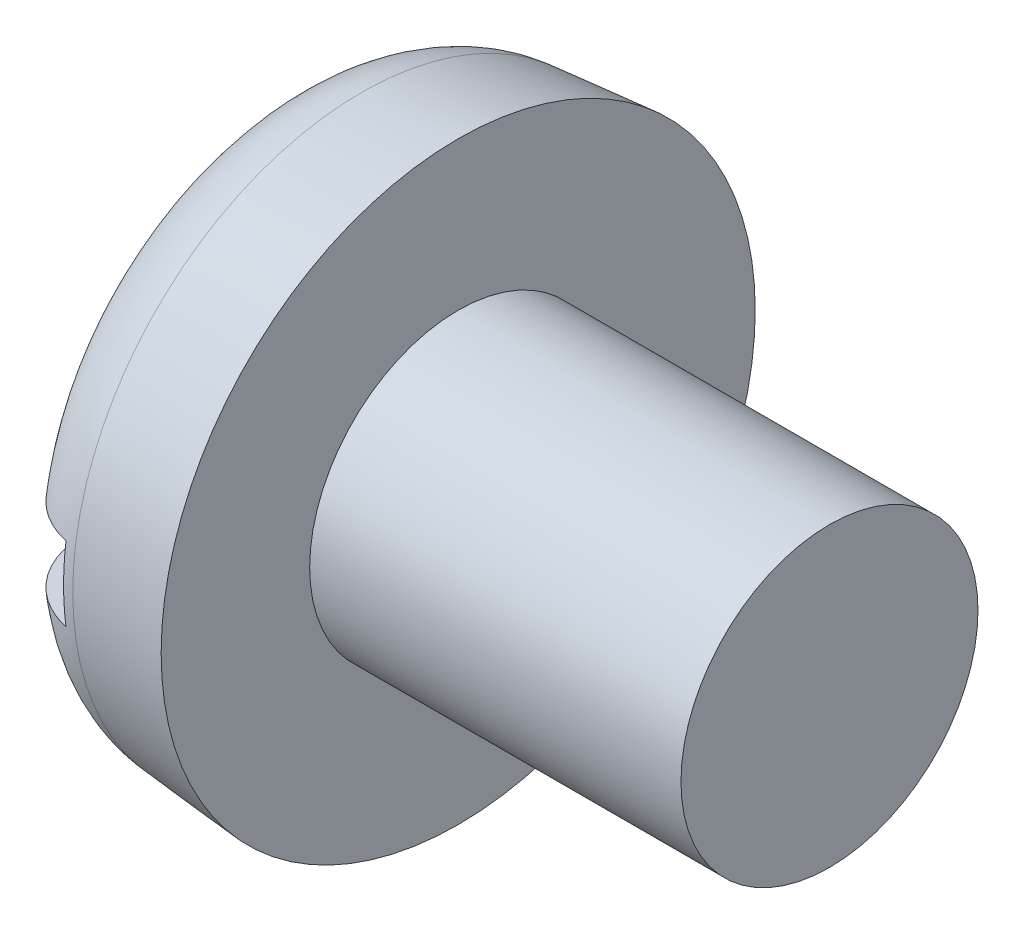
from build123d import *

# Parameters (mm, degrees)
FILLET2_R  = 2.4
SKETCH2_W  = 16
SKETCH2_H  = 2
SLOT_DEPTH = 1.9


with BuildPart() as part:
    # BodySke → Base-Revolve (revolve)
    with BuildSketch(Plane.XY, mode=Mode.PRIVATE) as base_revolve_sk:
        Polygon((4.8, 4), (4.8, 8), (0, 7.580054415), (0, 0), (14.8, 0), (14.8, 4), align=None)
    revolve(base_revolve_sk.sketch.rotate(Axis((-25.4, 0, 0), (1, 0, 0)), 90), axis=Axis((-25.4, 0, 0), (1, 0, 0)))  # turned: the seam where the file's is

    # Fillet2
    fillet2_edges = [part.edges().sort_by_distance(p)[0] for p in [
        (0, 0, -7.580054415),
    ]]
    fillet(fillet2_edges, radius=FILLET2_R)

    # Sketch2 → Slot (cut)
    with BuildSketch(Plane(origin=(0, 0, 0), x_dir=(0, 0, -1), z_dir=(1, 0, 0))):
        Rectangle(SKETCH2_W, SKETCH2_H)
    extrude(amount=SLOT_DEPTH, mode=Mode.SUBTRACT)


solid = part.part
